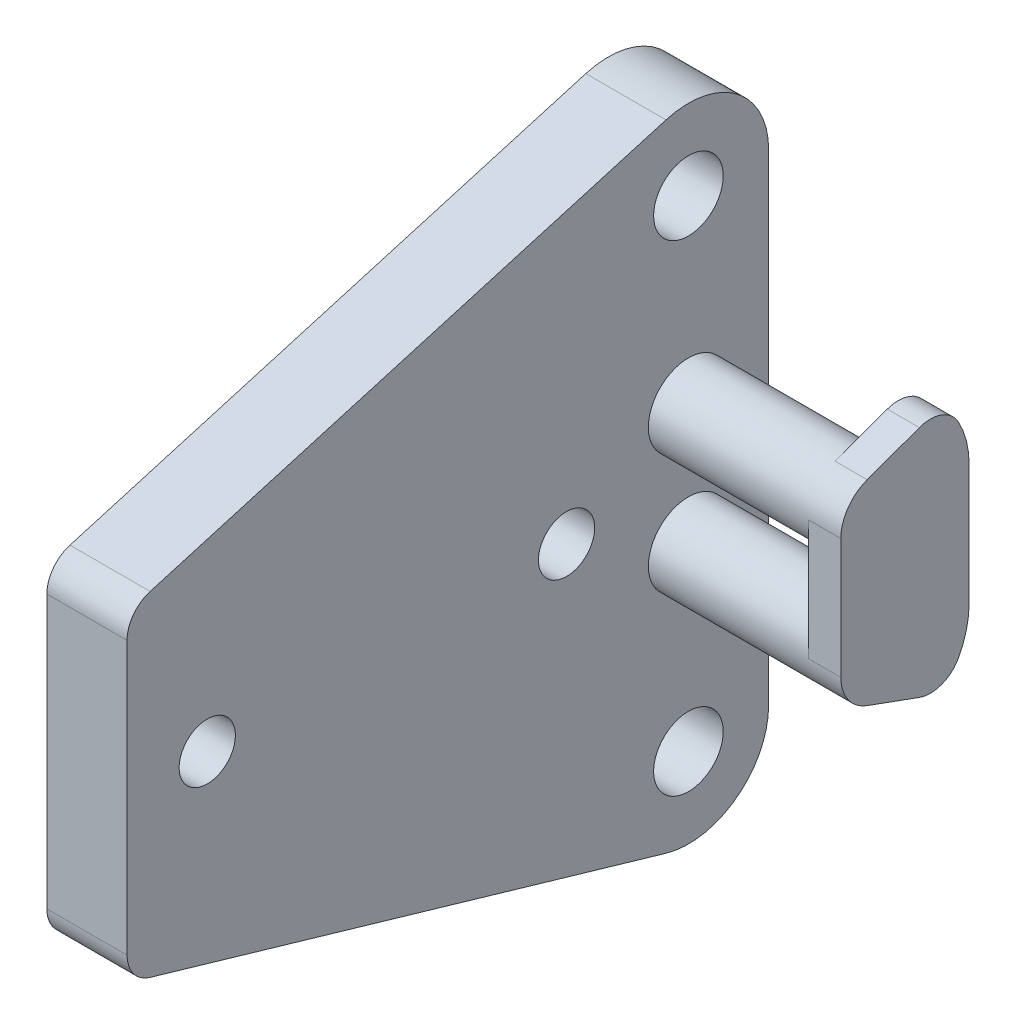
from build123d import *

# Parameters (mm, degrees)
SKETCH1_R           = 2.22670754
SKETCH1_R_2         = 2.7559
BOSS_EXTRUDE1_DEPTH = 6.35
SKETCH2_R           = 3.175
BOSS_EXTRUDE2_DEPTH = 12.7
BOSS_EXTRUDE3_DEPTH = 2.54
FILLET1_R           = 2.54


with BuildPart() as part:
    # Sketch1 → Boss-Extrude1 (new body)
    with BuildSketch(Plane(origin=(0, 0, 0), x_dir=(0, 0, -1), z_dir=(1, 0, 0))):
        with BuildLine():
            Line((-44.45, 12.7), (-44.45, -12.7))
            Line((-44.45, -12.7), (-1.778, -25.146))
            ThreePointArc((-1.778, -25.146), (3.81, -24.13), (6.35, -19.05))
            Line((6.35, -19.05), (6.35, 19.05))
            ThreePointArc((6.35, 19.05), (3.81, 24.13), (-1.778, 25.146))
            Line((-1.778, 25.146), (-44.45, 12.7))
        make_face()
        with Locations((-38.1, 0)):
            Circle(SKETCH1_R, mode=Mode.SUBTRACT)
        with Locations((-9.652, 0)):
            Circle(SKETCH1_R, mode=Mode.SUBTRACT)
        with Locations((0, -19.05)):
            Circle(SKETCH1_R_2, mode=Mode.SUBTRACT)
        with Locations((0, 19.05)):
            Circle(SKETCH1_R_2, mode=Mode.SUBTRACT)
    extrude(amount=-BOSS_EXTRUDE1_DEPTH)

    # Sketch2 → Boss-Extrude2 (add)
    with BuildSketch(Plane(origin=(0, 0, 0), x_dir=(0, 0, -1), z_dir=(1, 0, 0))):
        with Locations((0, -4.7625)):
            Circle(SKETCH2_R)
        with Locations((0, 4.7625)):
            Circle(SKETCH2_R)
    extrude(amount=BOSS_EXTRUDE2_DEPTH)

    # Sketch4 → Boss-Extrude3 (add)
    with BuildSketch(Plane(origin=(12.7, 0, 0), x_dir=(0, 0, -1), z_dir=(1, 0, 0))):
        with BuildLine():
            Line((-3.175, 4.7625), (-3.175, -4.7625))
            ThreePointArc((-3.175, -4.7625), (-2.600807741, -6.583605185), (-1.085913955, -7.746024071))
            Line((-1.085913955, -7.746024071), (4.760575332, -9.873972147))
            ThreePointArc((4.760575332, -9.873972147), (6.404796784, -7.549757281), (6.985, -4.7625))
            Line((6.985, -4.7625), (6.985, 4.7625))
            ThreePointArc((6.985, 4.7625), (6.404796784, 7.549757281), (4.760575332, 9.873972147))
            Line((4.760575332, 9.873972147), (-1.085913955, 7.746024071))
            ThreePointArc((-1.085913955, 7.746024071), (-2.600807741, 6.583605185), (-3.175, 4.7625))
        make_face()
    extrude(amount=BOSS_EXTRUDE3_DEPTH)

    # Fillet1
    fillet1_edges = [part.edges().sort_by_distance(p)[0] for p in [
        (-3.175, -12.7, 44.45),
        (-3.175, 12.7, 44.45),
        (13.97, -9.873972147, -4.760575332),
        (13.97, 9.873972147, -4.760575332),
    ]]
    fillet(fillet1_edges, radius=FILLET1_R)


solid = part.part
